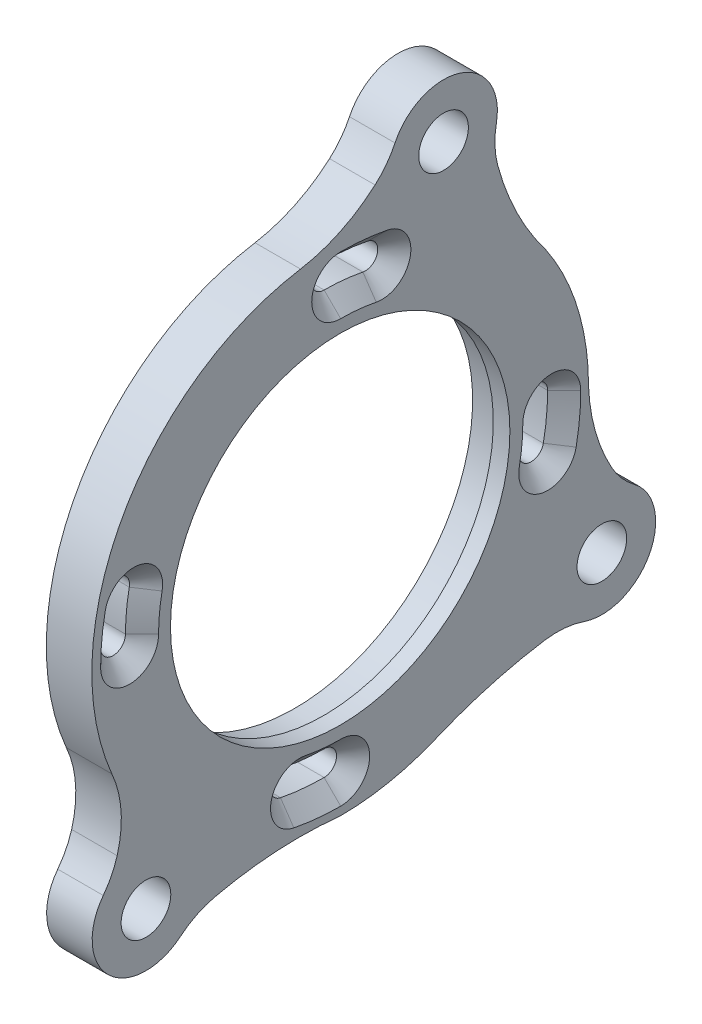
from build123d import *

# Parameters (mm, degrees)
ESQUISSE1_R             = 21.5
ESQUISSE1_R_2           = 20.5
BOSS_EXTRU_1_DEPTH      = 107
ESQUISSE2_R             = 20.5
ESQUISSE2_R_2           = 3
BOSS_EXTRU_2_DEPTH      = 5.5
CHANFREIN1_SIZE         = 2
CONG_1_R                = 10
ESQUISSE4_R             = 21.5
ESQUISSE4_R_2           = 20.5
ENL_V_MAT_EXTRU_2_DEPTH = 105


with BuildPart() as part:
    # Esquisse1 → Boss.-Extru.1 (new body)
    with BuildSketch(Plane(origin=(0, 0, 0), x_dir=(0, 0, -1), z_dir=(1, 0, 0))):
        Circle(ESQUISSE1_R)
        Circle(ESQUISSE1_R_2, mode=Mode.SUBTRACT)
    extrude(amount=BOSS_EXTRU_1_DEPTH)

    # Esquisse2 → Boss.-Extru.2 (add)
    with BuildSketch(Plane(origin=(107, 0, 0), x_dir=(0, 0, -1), z_dir=(1, 0, 0))):
        with BuildLine():
            ThreePointArc((6.205859778, 35.968559944), (14.711152146, 40.405222466), (18.372871483, 31.538668226))
            ThreePointArc((18.372871483, 31.538668226), (20.689295332, 23.844460332), (24.771129004, 16.923095695))
            ThreePointArc((24.771129004, 16.923095695), (28.662988941, 8.856244404), (30, 0))
            ThreePointArc((30, 0), (31.244976727, -6.50402438), (34.345135803, -12.355632184))
            ThreePointArc((34.345135803, -12.355632184), (37.237952026, -21.501974999), (27.870359387, -23.568900433))
            ThreePointArc((27.870359387, -23.568900433), (19.545131967, -25.015822985), (11.531193363, -27.69533498))
            ThreePointArc((11.531193363, -27.69533498), (5.879623738, -29.41819207), (0, -30))
            ThreePointArc((0, -30), (-9.148577813, -29.937932347), (-18.130212507, -31.678784611))
            ThreePointArc((-18.130212507, -31.678784611), (-27.639867217, -32.939911054), (-28.049234329, -23.355737059))
            ThreePointArc((-28.049234329, -23.355737059), (-26.447464851, -17.632677908), (-27.582285912, -11.799046736))
            ThreePointArc((-27.582285912, -11.799046736), (-26.28171566, 14.466216574), (-4.786405344, 29.615710761))
            ThreePointArc((-4.786405344, 29.615710761), (1.280514923, 31.804507658), (6.205859778, 35.968559944))
        make_face()
        Circle(ESQUISSE2_R, mode=Mode.SUBTRACT)
        with Locations((-23.461747754, -27.960622174)):
            Circle(ESQUISSE2_R_2, mode=Mode.SUBTRACT)
        with Locations((31.608959278, -18.251676453)):
            Circle(ESQUISSE2_R_2, mode=Mode.SUBTRACT)
        with Locations((12.487373333, 34.29745628)):
            Circle(ESQUISSE2_R_2, mode=Mode.SUBTRACT)
        with BuildLine():
            ThreePointArc((-26.420087149, 5.268613512), (-26.8090472, 2.647058824), (-26.939118291, 0))
            ThreePointArc((-26.939118291, 0), (-25.439118291, -1.5), (-23.939118291, 0))
            ThreePointArc((-23.939118291, 0), (-23.823499543, 2.352941176), (-23.477757276, 4.68321201))
            ThreePointArc((-23.477757276, 4.68321201), (-24.656221462, 6.447077698), (-26.420087149, 5.268613512))
        make_face(mode=Mode.SUBTRACT)
        with BuildLine():
            ThreePointArc((5.329495221, 26.480968858), (2.707940533, 26.869928909), (0.060881709, 27))
            ThreePointArc((0.060881709, 27), (-1.439118291, 25.5), (0.060881709, 24))
            ThreePointArc((0.060881709, 24), (2.413822886, 23.884381253), (4.74409372, 23.538638985))
            ThreePointArc((4.74409372, 23.538638985), (6.507959407, 24.717103171), (5.329495221, 26.480968858))
        make_face(mode=Mode.SUBTRACT)
        with BuildLine():
            ThreePointArc((26.541850567, -5.268613512), (26.930810618, -2.647058824), (27.060881709, 0))
            ThreePointArc((27.060881709, 0), (25.560881709, 1.5), (24.060881709, 0))
            ThreePointArc((24.060881709, 0), (23.945262962, -2.352941176), (23.599520694, -4.68321201))
            ThreePointArc((23.599520694, -4.68321201), (24.77798488, -6.447077698), (26.541850567, -5.268613512))
        make_face(mode=Mode.SUBTRACT)
        with BuildLine():
            ThreePointArc((-5.207731802, -26.480968858), (-2.586177114, -26.869928909), (0.060881709, -27))
            ThreePointArc((0.060881709, -27), (1.560881709, -25.5), (0.060881709, -24))
            ThreePointArc((0.060881709, -24), (-2.292059467, -23.884381253), (-4.622330301, -23.538638985))
            ThreePointArc((-4.622330301, -23.538638985), (-6.386195988, -24.717103171), (-5.207731802, -26.480968858))
        make_face(mode=Mode.SUBTRACT)
    extrude(amount=-BOSS_EXTRU_2_DEPTH)

    # Chanfrein1
    chanfrein1_edges = [part.edges().sort_by_distance(p)[0] for p in [
        (107, 6.447077698, 24.656221462),
        (107, 2.352941176, 23.823499543),
        (107, -1.5, 25.439118291),
        (107, 2.647058824, 26.8090472),
        (107, 24.717103171, -6.507959407),
        (107, 23.884381253, -2.413822886),
        (107, 25.5, 1.439118291),
        (107, 26.869928909, -2.707940533),
        (107, -6.447077698, -24.77798488),
        (107, -2.352941176, -23.945262962),
        (107, 1.5, -25.560881709),
        (107, -2.647058824, -26.930810618),
        (107, -24.717103171, 6.386195988),
        (107, -23.884381253, 2.292059467),
        (107, -25.5, -1.560881709),
        (107, -26.869928909, 2.586177114),
    ]]
    chamfer(chanfrein1_edges, length=CHANFREIN1_SIZE)

    # Congé1
    cong_1_edges = [part.edges().sort_by_distance(p)[0] for p in [
        (104.25, 35.968559944, -6.205859778),
        (104.25, 31.538668226, -18.372871483),
        (104.25, -12.355632184, -34.345135803),
        (104.25, -23.568900433, -27.870359387),
        (104.25, -31.678784611, 18.130212507),
        (104.25, -23.355737059, 28.049234329),
    ]]
    fillet(cong_1_edges, radius=CONG_1_R)

    # Esquisse4 → Enlèv. mat.-Extru.2 (cut)
    with BuildSketch(Plane.ZY):
        Circle(ESQUISSE4_R)
        Circle(ESQUISSE4_R_2, mode=Mode.SUBTRACT)
    extrude(amount=-ENL_V_MAT_EXTRU_2_DEPTH, mode=Mode.SUBTRACT)


solid = part.part
